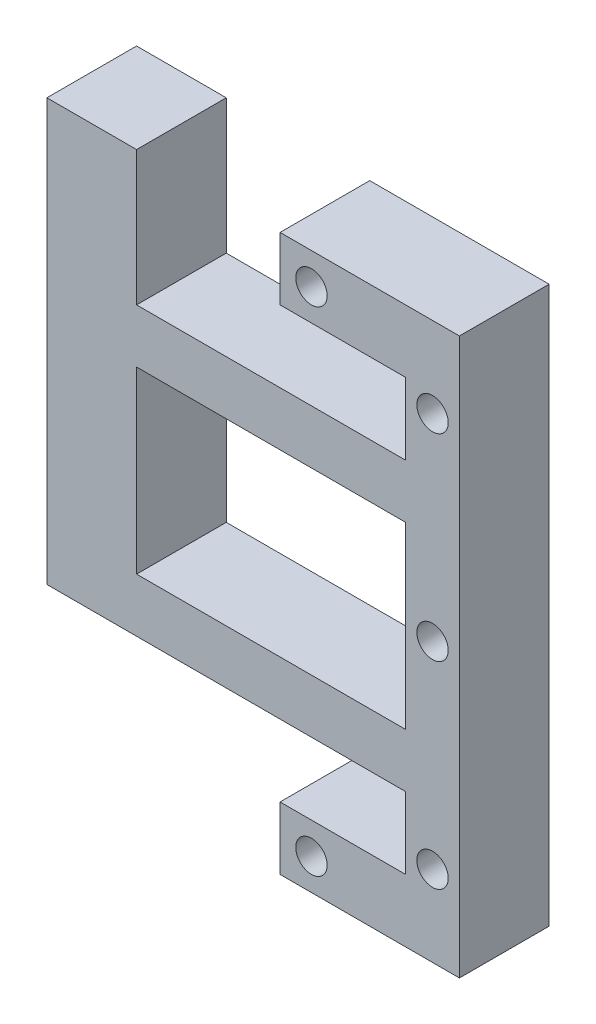
from build123d import *

# Parameters (mm, degrees)
SKETCH1_R           = 1.75
BOSS_EXTRUDE1_DEPTH = 10
BOSS_EXTRUDE2_DEPTH = 10


with BuildPart() as part:
    # Sketch1 → Boss-Extrude1 (new body)
    with BuildSketch(Plane.XY):
        Polygon((-2.419560872, 1), (11, 1), (11, 8), (11, 63), (-9, 63), (-9, 56), (5, 56), (5, 8), (-9, 8), (-9, 1), align=None)
        with Locations((-5.5, 59.5)):
            Circle(SKETCH1_R, mode=Mode.SUBTRACT)
        with Locations((8, 54)):
            Circle(SKETCH1_R, mode=Mode.SUBTRACT)
        with Locations((-5.5, 4.5)):
            Circle(SKETCH1_R, mode=Mode.SUBTRACT)
        with Locations((8, 10)):
            Circle(SKETCH1_R, mode=Mode.SUBTRACT)
        with Locations((8, 32)):
            Circle(SKETCH1_R, mode=Mode.SUBTRACT)
    extrude(amount=BOSS_EXTRUDE1_DEPTH)

    # Sketch2 → Boss-Extrude2 (add)
    with BuildSketch(Plane.XY.offset(10)):
        Polygon((5, 42), (5, 48), (-25, 48), (-25, 63), (-35, 63), (-35, 16), (5, 16), (5, 22), (-25, 22), (-25, 42), align=None)
    extrude(amount=-BOSS_EXTRUDE2_DEPTH)


solid = part.part
